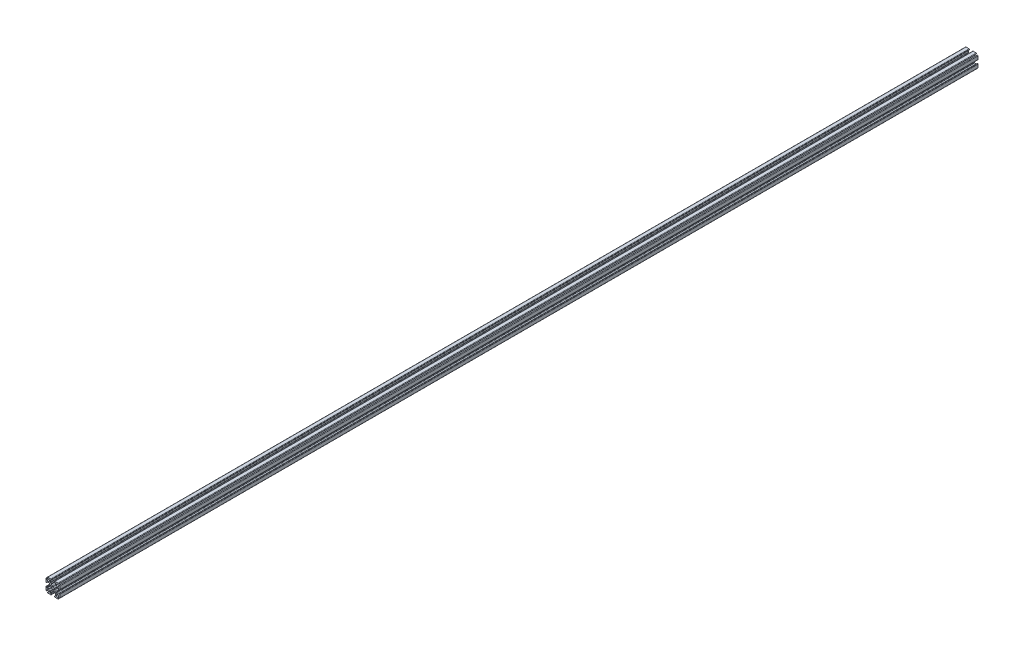
from build123d import *

# Parameters (mm, degrees)
SKETCH1_R    = 1.25
LENGTH_DEPTH = 1000.00054


with BuildPart() as part:
    # Sketch1 → Length (new body)
    with BuildSketch(Plane(origin=(0, 0, 0), x_dir=(-1, 0, 0), z_dir=(0, 0, -1))):
        with BuildLine():
            Line((6.646446609, 5.939339828), (6.163645978, 5.456539197))
            ThreePointArc((6.163645978, 5.456539197), (4.116116524, 4.116116524), (5.456539197, 6.163645978))
            Line((5.456539197, 6.163645978), (5.939339828, 6.646446609))
            ThreePointArc((5.939339828, 6.646446609), (6.047726204, 7.191341716), (5.585786438, 7.5))
            Line((5.585786438, 7.5), (2.25, 7.5))
            ThreePointArc((2.25, 7.5), (1.896446609, 7.353553391), (1.75, 7))
            Line((1.75, 7), (1.75, 6.8))
            ThreePointArc((1.75, 6.8), (1.896446609, 6.446446609), (2.25, 6.3))
            Line((2.25, 6.3), (2.65, 6.3))
            ThreePointArc((2.65, 6.3), (2.791421356, 6.241421356), (2.85, 6.1))
            Line((2.85, 6.1), (2.85, 4))
            ThreePointArc((2.85, 4), (2.703553391, 3.646446609), (2.35, 3.5))
            Line((2.35, 3.5), (2.1, 3.5))
            ThreePointArc((2.1, 3.5), (1.746446609, 3.353553391), (1.6, 3))
            ThreePointArc((1.6, 3), (1.307106781, 2.292893219), (0.6, 2))
            Line((0.6, 2), (-0.6, 2))
            ThreePointArc((-0.6, 2), (-1.307106781, 2.292893219), (-1.6, 3))
            ThreePointArc((-1.6, 3), (-1.746446609, 3.353553391), (-2.1, 3.5))
            Line((-2.1, 3.5), (-2.35, 3.5))
            ThreePointArc((-2.35, 3.5), (-2.703553391, 3.646446609), (-2.85, 4))
            Line((-2.85, 4), (-2.85, 6.1))
            ThreePointArc((-2.85, 6.1), (-2.791421356, 6.241421356), (-2.65, 6.3))
            Line((-2.65, 6.3), (-2.25, 6.3))
            ThreePointArc((-2.25, 6.3), (-1.896446609, 6.446446609), (-1.75, 6.8))
            Line((-1.75, 6.8), (-1.75, 7))
            ThreePointArc((-1.75, 7), (-1.896446609, 7.353553391), (-2.25, 7.5))
            Line((-2.25, 7.5), (-5.585786438, 7.5))
            ThreePointArc((-5.585786438, 7.5), (-6.047726204, 7.191341716), (-5.939339828, 6.646446609))
            Line((-5.939339828, 6.646446609), (-5.456539197, 6.163645978))
            ThreePointArc((-5.456539197, 6.163645978), (-4.116116524, 4.116116524), (-6.163645978, 5.456539197))
            Line((-6.163645978, 5.456539197), (-6.646446609, 5.939339828))
            ThreePointArc((-6.646446609, 5.939339828), (-7.191341716, 6.047726204), (-7.5, 5.585786438))
            Line((-7.5, 5.585786438), (-7.5, 2.25))
            ThreePointArc((-7.5, 2.25), (-7.353553391, 1.896446609), (-7, 1.75))
            Line((-7, 1.75), (-6.8, 1.75))
            ThreePointArc((-6.8, 1.75), (-6.446446609, 1.896446609), (-6.3, 2.25))
            Line((-6.3, 2.25), (-6.3, 2.65))
            ThreePointArc((-6.3, 2.65), (-6.241421356, 2.791421356), (-6.1, 2.85))
            Line((-6.1, 2.85), (-4, 2.85))
            ThreePointArc((-4, 2.85), (-3.646446609, 2.703553391), (-3.5, 2.35))
            Line((-3.5, 2.35), (-3.5, 2.1))
            ThreePointArc((-3.5, 2.1), (-3.353553391, 1.746446609), (-3, 1.6))
            ThreePointArc((-3, 1.6), (-2.292893219, 1.307106781), (-2, 0.6))
            Line((-2, 0.6), (-2, -0.6))
            ThreePointArc((-2, -0.6), (-2.292893219, -1.307106781), (-3, -1.6))
            ThreePointArc((-3, -1.6), (-3.353553391, -1.746446609), (-3.5, -2.1))
            Line((-3.5, -2.1), (-3.5, -2.35))
            ThreePointArc((-3.5, -2.35), (-3.646446609, -2.703553391), (-4, -2.85))
            Line((-4, -2.85), (-6.1, -2.85))
            ThreePointArc((-6.1, -2.85), (-6.241421356, -2.791421356), (-6.3, -2.65))
            Line((-6.3, -2.65), (-6.3, -2.25))
            ThreePointArc((-6.3, -2.25), (-6.446446609, -1.896446609), (-6.8, -1.75))
            Line((-6.8, -1.75), (-7, -1.75))
            ThreePointArc((-7, -1.75), (-7.353553391, -1.896446609), (-7.5, -2.25))
            Line((-7.5, -2.25), (-7.5, -5.585786438))
            ThreePointArc((-7.5, -5.585786438), (-7.191341716, -6.047726204), (-6.646446609, -5.939339828))
            Line((-6.646446609, -5.939339828), (-6.163645978, -5.456539197))
            ThreePointArc((-6.163645978, -5.456539197), (-4.116116524, -4.116116524), (-5.456539197, -6.163645978))
            Line((-5.456539197, -6.163645978), (-5.939339828, -6.646446609))
            ThreePointArc((-5.939339828, -6.646446609), (-6.047726204, -7.191341716), (-5.585786438, -7.5))
            Line((-5.585786438, -7.5), (-2.25, -7.5))
            ThreePointArc((-2.25, -7.5), (-1.896446609, -7.353553391), (-1.75, -7))
            Line((-1.75, -7), (-1.75, -6.8))
            ThreePointArc((-1.75, -6.8), (-1.896446609, -6.446446609), (-2.25, -6.3))
            Line((-2.25, -6.3), (-2.65, -6.3))
            ThreePointArc((-2.65, -6.3), (-2.791421356, -6.241421356), (-2.85, -6.1))
            Line((-2.85, -6.1), (-2.85, -4))
            ThreePointArc((-2.85, -4), (-2.703553391, -3.646446609), (-2.35, -3.5))
            Line((-2.35, -3.5), (-2.1, -3.5))
            ThreePointArc((-2.1, -3.5), (-1.746446609, -3.353553391), (-1.6, -3))
            ThreePointArc((-1.6, -3), (-1.307106781, -2.292893219), (-0.6, -2))
            Line((-0.6, -2), (0.6, -2))
            ThreePointArc((0.6, -2), (1.307106781, -2.292893219), (1.6, -3))
            ThreePointArc((1.6, -3), (1.746446609, -3.353553391), (2.1, -3.5))
            Line((2.1, -3.5), (2.35, -3.5))
            ThreePointArc((2.35, -3.5), (2.703553391, -3.646446609), (2.85, -4))
            Line((2.85, -4), (2.85, -6.1))
            ThreePointArc((2.85, -6.1), (2.791421356, -6.241421356), (2.65, -6.3))
            Line((2.65, -6.3), (2.25, -6.3))
            ThreePointArc((2.25, -6.3), (1.896446609, -6.446446609), (1.75, -6.8))
            Line((1.75, -6.8), (1.75, -7))
            ThreePointArc((1.75, -7), (1.896446609, -7.353553391), (2.25, -7.5))
            Line((2.25, -7.5), (5.585786438, -7.5))
            ThreePointArc((5.585786438, -7.5), (6.047726204, -7.191341716), (5.939339828, -6.646446609))
            Line((5.939339828, -6.646446609), (5.456539197, -6.163645978))
            ThreePointArc((5.456539197, -6.163645978), (4.116116524, -4.116116524), (6.163645978, -5.456539197))
            Line((6.163645978, -5.456539197), (6.646446609, -5.939339828))
            ThreePointArc((6.646446609, -5.939339828), (7.191341716, -6.047726204), (7.5, -5.585786438))
            Line((7.5, -5.585786438), (7.5, -2.25))
            ThreePointArc((7.5, -2.25), (7.353553391, -1.896446609), (7, -1.75))
            Line((7, -1.75), (6.8, -1.75))
            ThreePointArc((6.8, -1.75), (6.446446609, -1.896446609), (6.3, -2.25))
            Line((6.3, -2.25), (6.3, -2.65))
            ThreePointArc((6.3, -2.65), (6.241421356, -2.791421356), (6.1, -2.85))
            Line((6.1, -2.85), (4, -2.85))
            ThreePointArc((4, -2.85), (3.646446609, -2.703553391), (3.5, -2.35))
            Line((3.5, -2.35), (3.5, -2.1))
            ThreePointArc((3.5, -2.1), (3.353553391, -1.746446609), (3, -1.6))
            ThreePointArc((3, -1.6), (2.292893219, -1.307106781), (2, -0.6))
            Line((2, -0.6), (2, 0.6))
            ThreePointArc((2, 0.6), (2.292893219, 1.307106781), (3, 1.6))
            ThreePointArc((3, 1.6), (3.353553391, 1.746446609), (3.5, 2.1))
            Line((3.5, 2.1), (3.5, 2.35))
            ThreePointArc((3.5, 2.35), (3.646446609, 2.703553391), (4, 2.85))
            Line((4, 2.85), (6.1, 2.85))
            ThreePointArc((6.1, 2.85), (6.241421356, 2.791421356), (6.3, 2.65))
            Line((6.3, 2.65), (6.3, 2.25))
            ThreePointArc((6.3, 2.25), (6.446446609, 1.896446609), (6.8, 1.75))
            Line((6.8, 1.75), (7, 1.75))
            ThreePointArc((7, 1.75), (7.353553391, 1.896446609), (7.5, 2.25))
            Line((7.5, 2.25), (7.5, 5.585786438))
            ThreePointArc((7.5, 5.585786438), (7.191341716, 6.047726204), (6.646446609, 5.939339828))
        make_face()
        Circle(SKETCH1_R, mode=Mode.SUBTRACT)
    extrude(amount=-LENGTH_DEPTH)


solid = part.part
